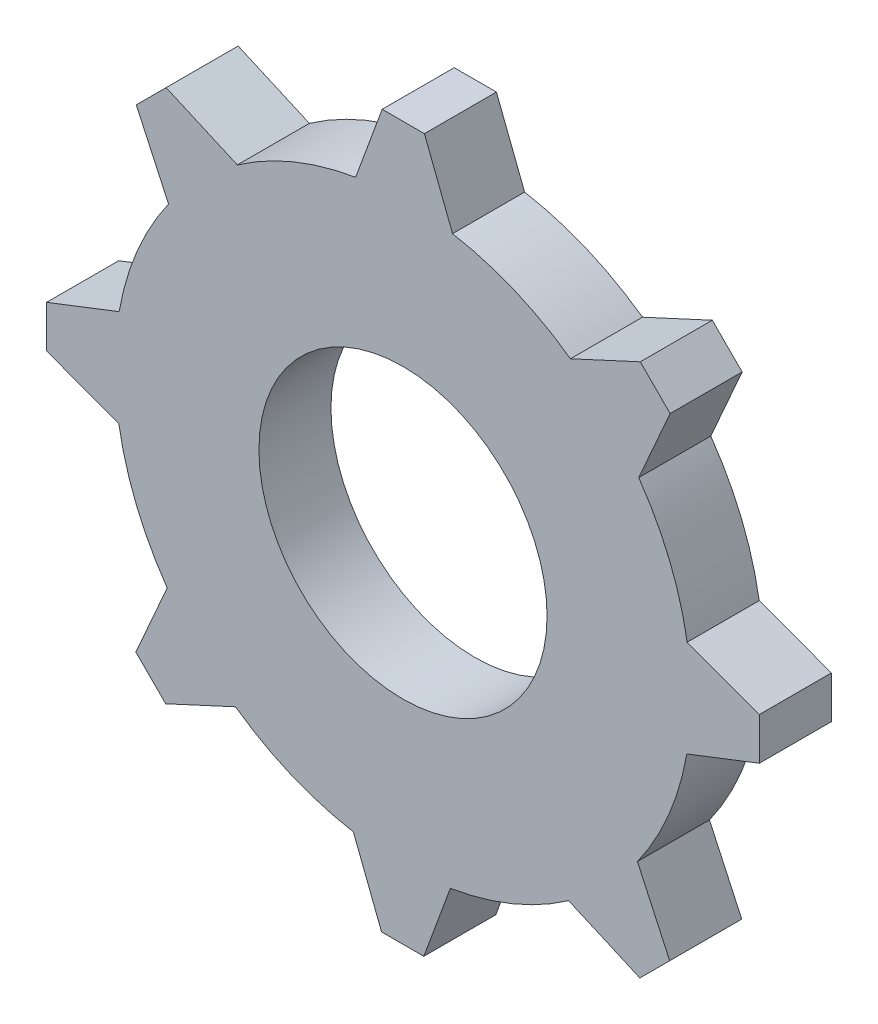
from build123d import *

# Parameters (mm, degrees)
CROQUIS1_R              = 8
CROQUIS1_R_2            = 4
SALIENTE_EXTRUIR5_DEPTH = 2
SALIENTE_EXTRUIR7_DEPTH = 2
MATRIZC5_COUNT          = 8


with BuildPart() as part:
    # Croquis1 → Saliente-Extruir5 (new body)
    with BuildSketch(Plane.XY):
        Circle(CROQUIS1_R)
        Circle(CROQUIS1_R_2, mode=Mode.SUBTRACT)
    extrude(amount=SALIENTE_EXTRUIR5_DEPTH)

    # Croquis5 → Saliente-Extruir7 (add)
    with BuildSketch(Plane.XY):
        Polygon((0.009306697, 9.894487771), (-0.577837412, 9.894487771), (-1.314748981, 7.891225198), (-1.314748981, 7.565133639), (1.376804344, 7.565133639), (1.376804344, 7.880635114), (0.594453217, 9.894487771), align=None)
    saliente_extruir7 = extrude(amount=SALIENTE_EXTRUIR7_DEPTH)

    # MatrizC5: Saliente-Extruir7 ×8 about axis
    matrizc5_axis = Axis((0, 0, 0), (0, 0, 1))
    for i in range(1, MATRIZC5_COUNT):
        add(saliente_extruir7.rotate(matrizc5_axis, i * 360 / MATRIZC5_COUNT))


solid = part.part
